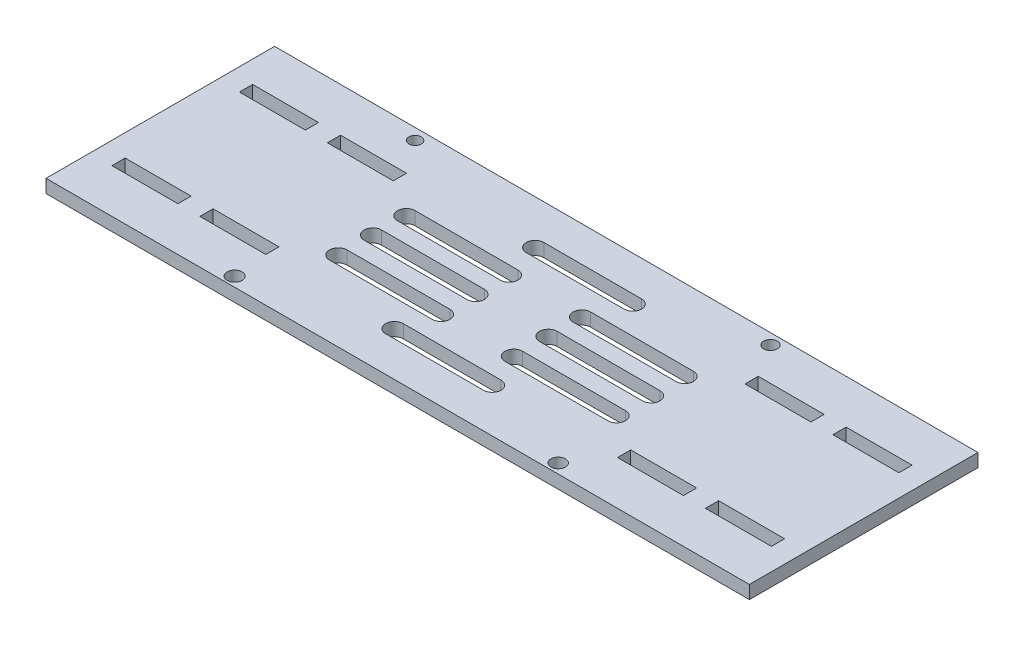
from build123d import *

# Parameters (mm, degrees)
SKETCH1_W           = 160
SKETCH1_H           = 52
SKETCH1_W_2         = 15
SKETCH1_H_2         = 3
BOSS_EXTRUDE1_DEPTH = 3
CUT_EXTRUDE1_DEPTH  = 3
SKETCH3_R           = 1.63582752
SKETCH3_R_2         = 1.692495787
SKETCH3_R_3         = 1.410083192
SKETCH3_R_4         = 1.550817753
CUT_EXTRUDE2_DEPTH  = 10


with BuildPart() as part:
    # Sketch1 → Boss-Extrude1 (new body)
    with BuildSketch(Plane(origin=(0, 0, 0), x_dir=(1, 0, 0), z_dir=(0, 1, 0))):
        Rectangle(SKETCH1_W, SKETCH1_H)
        with Locations((67.5, 14.5)):
            Rectangle(SKETCH1_W_2, SKETCH1_H_2, mode=Mode.SUBTRACT)
        with Locations((47.5, 14.5)):
            Rectangle(SKETCH1_W_2, SKETCH1_H_2, mode=Mode.SUBTRACT)
        with Locations((67.5, -14.5)):
            Rectangle(SKETCH1_W_2, SKETCH1_H_2, mode=Mode.SUBTRACT)
        with Locations((47.5, -14.5)):
            Rectangle(SKETCH1_W_2, SKETCH1_H_2, mode=Mode.SUBTRACT)
        with Locations((-47.5, -14.5)):
            Rectangle(SKETCH1_W_2, SKETCH1_H_2, mode=Mode.SUBTRACT)
        with Locations((-67.5, -14.5)):
            Rectangle(SKETCH1_W_2, SKETCH1_H_2, mode=Mode.SUBTRACT)
        with Locations((-47.5, 14.5)):
            Rectangle(SKETCH1_W_2, SKETCH1_H_2, mode=Mode.SUBTRACT)
        with Locations((-67.5, 14.5)):
            Rectangle(SKETCH1_W_2, SKETCH1_H_2, mode=Mode.SUBTRACT)
    extrude(amount=BOSS_EXTRUDE1_DEPTH)

    # Sketch2 → Cut-Extrude1 (cut)
    with BuildSketch(Plane(origin=(0, 3, 0), x_dir=(1, 0, 0), z_dir=(0, 1, 0))):
        with BuildLine():
            Line((-31.658505885, 2), (-8.266387648, 2))
            ThreePointArc((-8.266387648, 2), (-6.266387648, 0), (-8.266387648, -2))
            Line((-8.266387648, -2), (-31.658505885, -2))
            ThreePointArc((-31.658505885, -2), (-33.658505885, 0), (-31.658505885, 2))
        make_face()
        with BuildLine():
            Line((31.658505885, -9.856733432), (8.266387648, -9.856733432))
            ThreePointArc((8.266387648, -9.856733432), (6.266387648, -7.856733432), (8.266387648, -5.856733432))
            Line((8.266387648, -5.856733432), (31.658505885, -5.856733432))
            ThreePointArc((31.658505885, -5.856733432), (33.658505885, -7.856733432), (31.658505885, -9.856733432))
        make_face()
        with BuildLine():
            Line((-10.747740664, 17.987567994), (11.499478158, 17.987567994))
            ThreePointArc((11.499478158, 17.987567994), (13.499478158, 15.987567994), (11.499478158, 13.987567994))
            Line((11.499478158, 13.987567994), (-10.747740664, 13.987567994))
            ThreePointArc((-10.747740664, 13.987567994), (-12.747740664, 15.987567994), (-10.747740664, 17.987567994))
        make_face()
        with BuildLine():
            Line((-31.658505885, 9.620758334), (-8.266387648, 9.620758334))
            ThreePointArc((-8.266387648, 9.620758334), (-6.266387648, 7.620758334), (-8.266387648, 5.620758334))
            Line((-8.266387648, 5.620758334), (-31.658505885, 5.620758334))
            ThreePointArc((-31.658505885, 5.620758334), (-33.658505885, 7.620758334), (-31.658505885, 9.620758334))
        make_face()
        with BuildLine():
            Line((31.658505885, 5.620758334), (8.266387648, 5.620758334))
            ThreePointArc((8.266387648, 5.620758334), (6.266387648, 7.620758334), (8.266387648, 9.620758334))
            Line((8.266387648, 9.620758334), (31.658505885, 9.620758334))
            ThreePointArc((31.658505885, 9.620758334), (33.658505885, 7.620758334), (31.658505885, 5.620758334))
        make_face()
        with BuildLine():
            Line((-31.658505885, -5.856733432), (-8.266387648, -5.856733432))
            ThreePointArc((-8.266387648, -5.856733432), (-6.266387648, -7.856733432), (-8.266387648, -9.856733432))
            Line((-8.266387648, -9.856733432), (-31.658505885, -9.856733432))
            ThreePointArc((-31.658505885, -9.856733432), (-33.658505885, -7.856733432), (-31.658505885, -5.856733432))
        make_face()
        with BuildLine():
            Line((31.658505885, -2), (8.266387648, -2))
            ThreePointArc((8.266387648, -2), (6.266387648, 0), (8.266387648, 2))
            Line((8.266387648, 2), (31.658505885, 2))
            ThreePointArc((31.658505885, 2), (33.658505885, 0), (31.658505885, -2))
        make_face()
        with BuildLine():
            Line((-10.747740664, -13.987567994), (11.499478158, -13.987567994))
            ThreePointArc((11.499478158, -13.987567994), (13.499478158, -15.987567994), (11.499478158, -17.987567994))
            Line((11.499478158, -17.987567994), (-10.747740664, -17.987567994))
            ThreePointArc((-10.747740664, -17.987567994), (-12.747740664, -15.987567994), (-10.747740664, -13.987567994))
        make_face()
    extrude(amount=-CUT_EXTRUDE1_DEPTH, mode=Mode.SUBTRACT)

    # Sketch3 → Cut-Extrude2 (cut)
    with BuildSketch(Plane(origin=(0, 3, 0), x_dir=(1, 0, 0), z_dir=(0, 1, 0))):
        with Locations((34.323103301, -23.81549711)):
            Circle(SKETCH3_R)
        with Locations((-39.276258797, -23.81549711)):
            Circle(SKETCH3_R_2)
        with Locations((-45.484369153, 23.437784188)):
            Circle(SKETCH3_R_3)
        with Locations((35.235754497, 23.565498985)):
            Circle(SKETCH3_R_4)
    extrude(amount=-CUT_EXTRUDE2_DEPTH, mode=Mode.SUBTRACT)


solid = part.part
